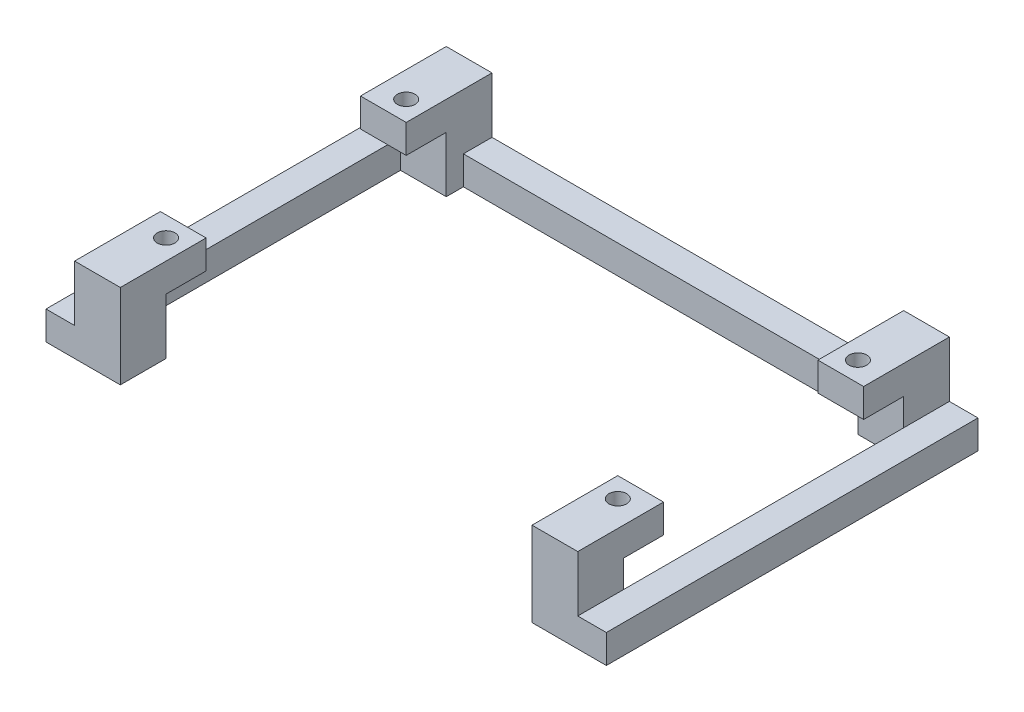
from build123d import *

# Parameters (mm, degrees)
SKETCH1_W             = 7
SKETCH1_H             = 7
BOSS_EXTRUDE1_DEPTH   = 5
BOSS_EXTRUDE1_2_DEPTH = 5
BOSS_EXTRUDE1_3_DEPTH = 5
BOSS_EXTRUDE1_4_DEPTH = 5
SKETCH2_R             = 1.55
CUT_EXTRUDE1_DEPTH    = 6
SKETCH4_W             = 8
SKETCH4_H             = 8
BOSS_EXTRUDE3_DEPTH   = 14.76
BOSS_EXTRUDE4_DEPTH   = 5
SKETCH6_R             = 1.0795
CUT_EXTRUDE2_DEPTH    = 10
SKETCH7_W             = 1
SKETCH7_H             = 7
BOSS_EXTRUDE5_DEPTH   = 5


with BuildPart() as part:
    # Sketch1 → Boss-Extrude1 (new body)
    with BuildSketch(Plane(origin=(0, 0, 0), x_dir=(1, 0, 0), z_dir=(0, 1, 0))):
        with Locations((-39.5, 21)):
            Rectangle(SKETCH1_W, SKETCH1_H)
    extrude(amount=BOSS_EXTRUDE1_DEPTH)


with BuildPart() as body_2:
    # Sketch1 → Boss-Extrude1 2 (new body)
    with BuildSketch(Plane(origin=(0, 0, 0), x_dir=(1, 0, 0), z_dir=(0, 1, 0))):
        with Locations((39.5, 21)):
            Rectangle(SKETCH1_W, SKETCH1_H)
    extrude(amount=BOSS_EXTRUDE1_2_DEPTH)


with BuildPart() as body_3:
    # Sketch1 → Boss-Extrude1 3 (new body)
    with BuildSketch(Plane(origin=(0, 0, 0), x_dir=(1, 0, 0), z_dir=(0, 1, 0))):
        with Locations((-39.5, -21)):
            Rectangle(SKETCH1_W, SKETCH1_H)
    extrude(amount=BOSS_EXTRUDE1_3_DEPTH)


with BuildPart() as body_4:
    # Sketch1 → Boss-Extrude1 4 (new body)
    with BuildSketch(Plane(origin=(0, 0, 0), x_dir=(1, 0, 0), z_dir=(0, 1, 0))):
        with Locations((39.5, -21)):
            Rectangle(SKETCH1_W, SKETCH1_H)
    extrude(amount=BOSS_EXTRUDE1_4_DEPTH)


with BuildPart() as cut_extrude1_tool:
    # Sketch2 → Cut-Extrude1 (new body, through all)
    with BuildSketch(Plane(origin=(0, 5, 0), x_dir=(1, 0, 0), z_dir=(0, 1, 0))):
        with Locations((-39.5, 21)):
            Circle(SKETCH2_R)
        with Locations((39.5, 21)):
            Circle(SKETCH2_R)
        with Locations((39.5, -21)):
            Circle(SKETCH2_R)
        with Locations((-39.5, -21)):
            Circle(SKETCH2_R)
    extrude(amount=-CUT_EXTRUDE1_DEPTH)


with BuildPart() as part_1:
    add(part.part)

    # Cut-Extrude1: cut by cut_extrude1_tool
    add(cut_extrude1_tool.part, mode=Mode.SUBTRACT)



with BuildPart() as body_2_1:
    add(body_2.part)

    # Cut-Extrude1: cut by cut_extrude1_tool
    add(cut_extrude1_tool.part, mode=Mode.SUBTRACT)


with BuildPart() as body_3_1:
    add(body_3.part)

    # Cut-Extrude1: cut by cut_extrude1_tool
    add(cut_extrude1_tool.part, mode=Mode.SUBTRACT)


with BuildPart() as body_4_1:
    add(body_4.part)

    # Cut-Extrude1: cut by cut_extrude1_tool
    add(cut_extrude1_tool.part, mode=Mode.SUBTRACT)


with BuildPart() as part_2:
    add(part_1.part)

    add(body_2_1.part)  # Boss-Extrude3 merges body 2

    add(body_3_1.part)  # Boss-Extrude3 merges body 3

    add(body_4_1.part)  # Boss-Extrude3 merges body 4
    # Sketch4 → Boss-Extrude3 (add)
    with BuildSketch(Plane(origin=(0, 5, 0), x_dir=(1, 0, 0), z_dir=(0, 1, 0))):
        with Locations((40, 28.5)):
            Rectangle(SKETCH4_W, SKETCH4_H)
        with Locations((40, -28.5)):
            Rectangle(SKETCH4_W, SKETCH4_H)
        with Locations((-40, -28.5)):
            Rectangle(SKETCH4_W, SKETCH4_H)
        with Locations((-40, 28.5)):
            Rectangle(SKETCH4_W, SKETCH4_H)
    extrude(amount=-BOSS_EXTRUDE3_DEPTH)

    # Sketch5 → Boss-Extrude4 (add)
    with BuildSketch(Plane.XZ.offset(9.76)):
        Polygon((-49, 32.5), (-49, -32.5), (49, -32.5), (49, 32.5), (44, 32.5), (44, -27.5), (-44, -27.5), (-44, 32.5), align=None)
    extrude(amount=-BOSS_EXTRUDE4_DEPTH)

    # Sketch6 → Cut-Extrude2 (cut)
    with BuildSketch(Plane(origin=(0, -4.76, 0), x_dir=(-1, 0, 0), z_dir=(0, 1, 0))):
        with Locations((40, 28.5)):
            Circle(SKETCH6_R)
        with Locations((40, -28.5)):
            Circle(SKETCH6_R)
        with Locations((-40, -28.5)):
            Circle(SKETCH6_R)
        with Locations((-40, 28.5)):
            Circle(SKETCH6_R)
    extrude(amount=-CUT_EXTRUDE2_DEPTH, mode=Mode.SUBTRACT)

    # Sketch7 → Boss-Extrude5 (add)
    with BuildSketch(Plane(origin=(0, 5, 0), x_dir=(1, 0, 0), z_dir=(0, 1, 0))):
        with Locations((43.5, -21)):
            Rectangle(SKETCH7_W, SKETCH7_H)
        with Locations((43.5, 21)):
            Rectangle(SKETCH7_W, SKETCH7_H)
        with Locations((-43.5, 21)):
            Rectangle(SKETCH7_W, SKETCH7_H)
        with Locations((-43.5, -21)):
            Rectangle(SKETCH7_W, SKETCH7_H)
    extrude(amount=-BOSS_EXTRUDE5_DEPTH)


solid = part_2.part
